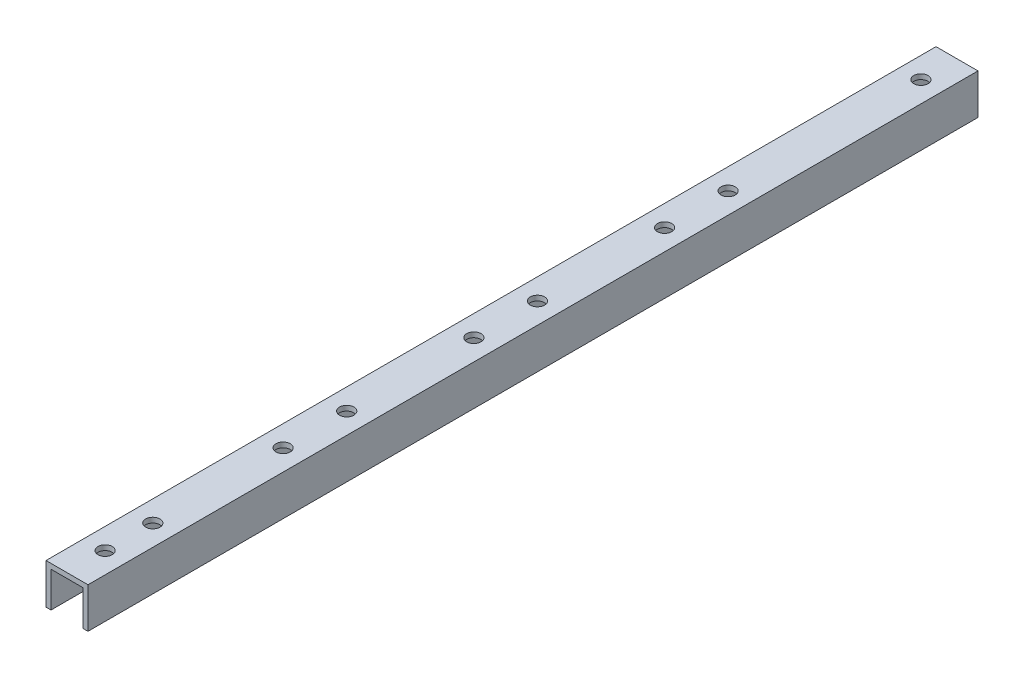
from build123d import *

# Parameters (mm, degrees)
BOSS_EXTRUDE1_DEPTH      = 20
BOSS_EXTRUDE1_DEPTH_BACK = 260
M4_CLEARANCE_HOLE1_D     = 4.5
M4_CLEARANCE_HOLE2_D     = 4.5


with BuildPart() as part:
    # Sketch1 → Boss-Extrude1 (new body, two sides)
    with BuildSketch(Plane.XY) as boss_extrude1_sk:
        Polygon((-6.604, 0), (6.604, 0), (6.604, -12.7), (5.0165, -12.7), (5.0165, -1.5875), (-5.0165, -1.5875), (-5.0165, -12.7), (-6.604, -12.7), align=None)
    extrude(amount=BOSS_EXTRUDE1_DEPTH)
    extrude(boss_extrude1_sk.sketch, amount=-BOSS_EXTRUDE1_DEPTH_BACK)

    # M4 Clearance Hole1 (through all)
    with Locations(Plane(origin=(0, 0, 0), x_dir=(1, 0, 0), z_dir=(0, 1, 0))):
        with Locations((0, 7), (0, 248.64)):
            Hole(M4_CLEARANCE_HOLE1_D / 2)

    # M4 Clearance Hole2 (through all)
    with Locations(Plane(origin=(0, 0, 0), x_dir=(1, 0, 0), z_dir=(0, 1, 0))):
        with Locations((0, 108), (0, 128), (0, -8), (0, 188), (0, 168), (0, 68), (0, 48)):
            Hole(M4_CLEARANCE_HOLE2_D / 2)


solid = part.part
